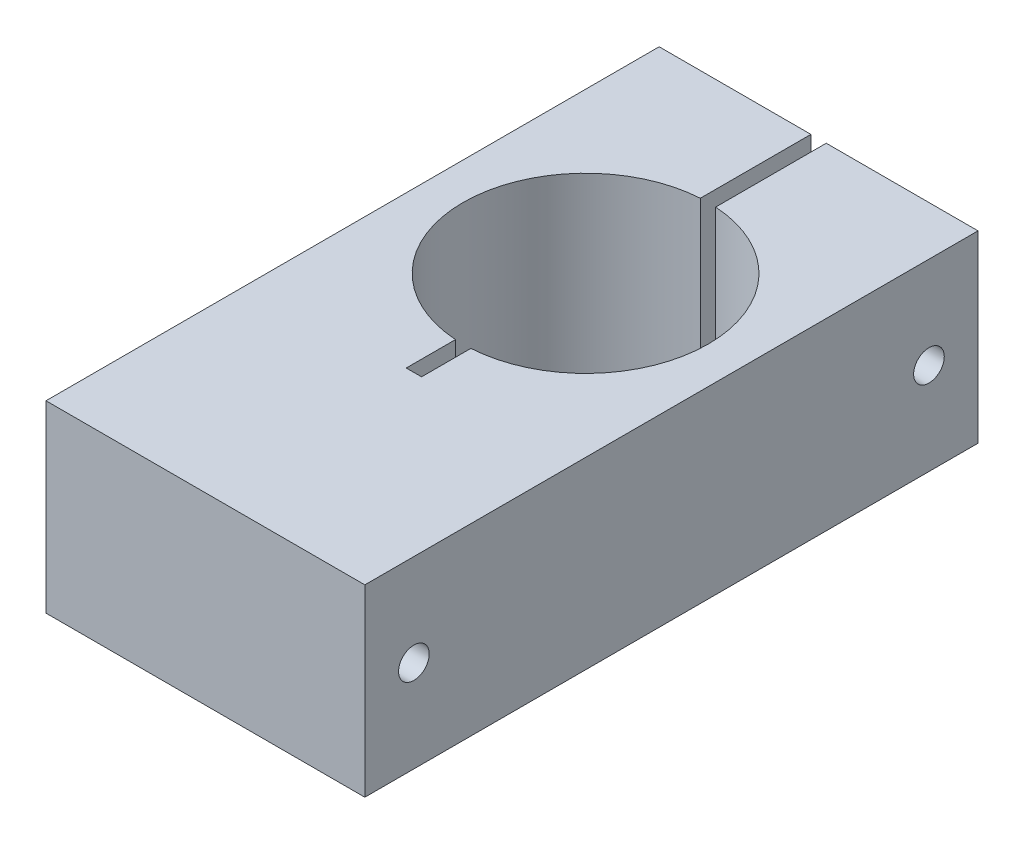
from build123d import *

# Parameters (mm, degrees)
SKETCH1_W           = 33.02
SKETCH1_H           = 63.5
BOSS_EXTRUDE1_DEPTH = 19.05
CUT_EXTRUDE1_DEPTH  = 19.05
SKETCH3_R           = 12.7
CUT_EXTRUDE2_DEPTH  = 19.05
SKETCH4_R           = 1.5875
CUT_EXTRUDE3_DEPTH  = 33.02


with BuildPart() as part:
    # Sketch1 → Boss-Extrude1 (new body)
    with BuildSketch(Plane(origin=(0, 0, 0), x_dir=(1, 0, 0), z_dir=(0, 1, 0))):
        Rectangle(SKETCH1_W, SKETCH1_H)
    extrude(amount=BOSS_EXTRUDE1_DEPTH)

    # Sketch2 → Cut-Extrude1 (cut)
    with BuildSketch(Plane(origin=(0, 19.05, 0), x_dir=(1, 0, 0), z_dir=(0, 1, 0))):
        Polygon((0, 31.75), (0.79375, 31.75), (0.79375, -10.16), (-0.79375, -10.16), (-0.79375, 31.75), align=None)
    extrude(amount=-CUT_EXTRUDE1_DEPTH, mode=Mode.SUBTRACT)

    # Sketch3 → Cut-Extrude2 (cut)
    with BuildSketch(Plane(origin=(0, 19.05, 0), x_dir=(1, 0, 0), z_dir=(0, 1, 0))):
        with Locations((0, 7.62)):
            Circle(SKETCH3_R)
    extrude(amount=-CUT_EXTRUDE2_DEPTH, mode=Mode.SUBTRACT)

    # Sketch4 → Cut-Extrude3 (cut)
    with BuildSketch(Plane(origin=(16.51, 0, 0), x_dir=(0, 0, -1), z_dir=(1, 0, 0))):
        with Locations((-26.67, 9.525)):
            Circle(SKETCH4_R)
        with Locations((26.67, 9.525)):
            Circle(SKETCH4_R)
    extrude(amount=-CUT_EXTRUDE3_DEPTH, mode=Mode.SUBTRACT)


solid = part.part
